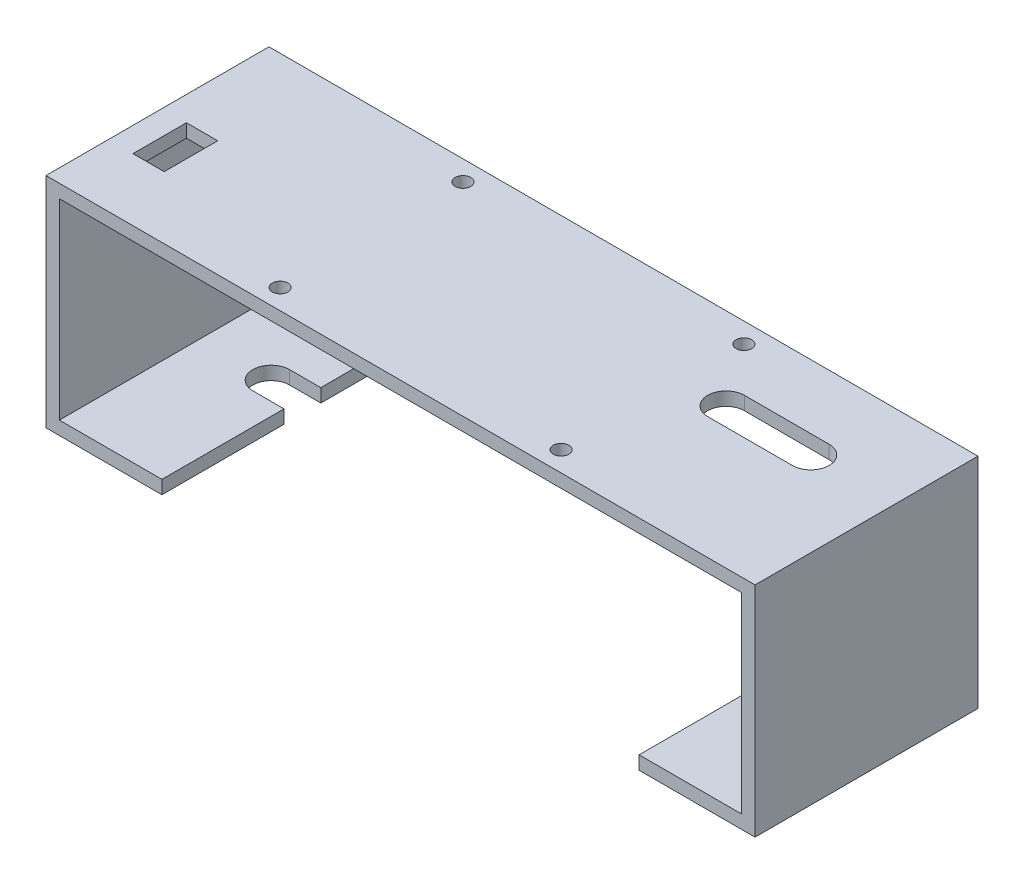
from build123d import *

# Parameters (mm, degrees)
BOSS_EXTRUDE1_DEPTH = 3
BOSS_EXTRUDE2_DEPTH = 50
CUT_EXTRUDE1_REACH  = 51
CUT_EXTRUDE2_REACH  = 5
CUT_EXTRUDE3_REACH  = 51
SKETCH7_W           = 7
SKETCH7_H           = 12
CUT_EXTRUDE5_REACH  = 51
SKETCH8_W           = 7
SKETCH8_H           = 12
CUT_EXTRUDE7_REACH  = 5
SKETCH1_R           = 1.75


with BuildPart() as part:
    # Sketch2 → Boss-Extrude1 (new body)
    with BuildSketch(Plane(origin=(0, 0, 0), x_dir=(1, 0, 0), z_dir=(0, 1, 0))):
        Polygon((-52.5, 25), (52.5, 25), (76.5, 25), (79.5, 25), (79.5, -25), (76.5, -25), (52.5, -25), (-52.5, -25), (-76.5, -25), (-79.5, -25), (-79.5, 25), (-76.5, 25), align=None)
    extrude(amount=BOSS_EXTRUDE1_DEPTH)

    # Sketch4 → Boss-Extrude2 (add)
    with BuildSketch(Plane(origin=(0, 0, -25), x_dir=(-1, 0, 0), z_dir=(0, 0, -1))):
        Polygon((79.5, 0), (79.5, -46), (53.5, -46), (53.5, -43), (76.5, -43), (76.5, 0), align=None)
    boss_extrude2 = extrude(amount=-BOSS_EXTRUDE2_DEPTH)

    # Mirror1: Boss-Extrude2 across plane
    add(boss_extrude2.mirror(Plane(origin=(0, 0, 0), x_dir=(0, 0, 1), z_dir=(1, 0, 0))))

    # Sketch5 → Cut-Extrude1 (cut, up to next)
    with BuildSketch(Plane.XZ.offset(46), mode=Mode.PRIVATE) as cut_extrude1_sk1:
        with BuildLine():
            Line((-53.5, -2.375), (-60.5, -2.375))
            ThreePointArc((-60.5, -2.375), (-64.625, -6.5), (-60.5, -10.625))
            Line((-60.5, -10.625), (-53.5, -10.625))
            Line((-53.5, -10.625), (-53.5, -2.375))
        make_face()
    cut_extrude1_tool1 = extrude(cut_extrude1_sk1.sketch, amount=-CUT_EXTRUDE1_REACH, mode=Mode.PRIVATE) & part.part
    add(cut_extrude1_tool1.solids().sort_by_distance((-58.661274, -46, -6.5))[0], mode=Mode.SUBTRACT)

    # Sketch6 → Cut-Extrude2 (cut, up to next)
    with BuildSketch(Plane.XZ, mode=Mode.PRIVATE) as cut_extrude2_sk1:
        with BuildLine():
            Line((41.5, -2.375), (60.5, -2.375))
            ThreePointArc((60.5, -2.375), (64.625, -6.5), (60.5, -10.625))
            Line((60.5, -10.625), (41.5, -10.625))
            ThreePointArc((41.5, -10.625), (37.375, -6.5), (41.5, -2.375))
        make_face()
    cut_extrude2_tool1 = extrude(cut_extrude2_sk1.sketch, amount=-CUT_EXTRUDE2_REACH, mode=Mode.PRIVATE) & part.part
    add(cut_extrude2_tool1.solids().sort_by_distance((51, 0, -6.5))[0], mode=Mode.SUBTRACT)

    # Sketch7 → Cut-Extrude3 (cut, up to next)
    with BuildSketch(Plane.XZ.offset(46), mode=Mode.PRIVATE) as cut_extrude3_sk1:
        with Locations((70.5, 5)):
            Rectangle(SKETCH7_W, SKETCH7_H)
    cut_extrude3_tool1 = extrude(cut_extrude3_sk1.sketch, amount=-CUT_EXTRUDE3_REACH, mode=Mode.PRIVATE) & part.part
    add(cut_extrude3_tool1.solids().sort_by_distance((70.5, -46, 5))[0], mode=Mode.SUBTRACT)

    # Sketch8 → Cut-Extrude5 (cut, up to next)
    with BuildSketch(Plane(origin=(0, 3, 0), x_dir=(1, 0, 0), z_dir=(0, 1, 0)), mode=Mode.PRIVATE) as cut_extrude5_sk1:
        with Locations((-70.5, -5)):
            Rectangle(SKETCH8_W, SKETCH8_H)
    cut_extrude5_tool1 = extrude(cut_extrude5_sk1.sketch, amount=-CUT_EXTRUDE5_REACH, mode=Mode.PRIVATE) & part.part
    add(cut_extrude5_tool1.solids().sort_by_distance((-70.5, 3, 5))[0], mode=Mode.SUBTRACT)

    # Sketch1 → Cut-Extrude7 (cut, up to next)
    with BuildSketch(Plane(origin=(0, 0, 0), x_dir=(1, 0, 0), z_dir=(0, 1, 0)), mode=Mode.PRIVATE) as cut_extrude7_sk1:
        with Locations((-31.5, 20.5)):
            Circle(SKETCH1_R)
    cut_extrude7_tool1 = extrude(cut_extrude7_sk1.sketch, amount=CUT_EXTRUDE7_REACH, mode=Mode.PRIVATE) & part.part
    add(cut_extrude7_tool1.solids().sort_by_distance((-31.5, 0, -20.5))[0], mode=Mode.SUBTRACT)
    # Sketch1 → Cut-Extrude7 (cut, up to next)
    with BuildSketch(Plane(origin=(0, 0, 0), x_dir=(1, 0, 0), z_dir=(0, 1, 0)), mode=Mode.PRIVATE) as cut_extrude7_sk2:
        with Locations((-31.5, -20.5)):
            Circle(SKETCH1_R)
    cut_extrude7_tool2 = extrude(cut_extrude7_sk2.sketch, amount=CUT_EXTRUDE7_REACH, mode=Mode.PRIVATE) & part.part
    add(cut_extrude7_tool2.solids().sort_by_distance((-31.5, 0, 20.5))[0], mode=Mode.SUBTRACT)
    # Sketch1 → Cut-Extrude7 (cut, up to next)
    with BuildSketch(Plane(origin=(0, 0, 0), x_dir=(1, 0, 0), z_dir=(0, 1, 0)), mode=Mode.PRIVATE) as cut_extrude7_sk3:
        with Locations((31.5, -20.5)):
            Circle(SKETCH1_R)
    cut_extrude7_tool3 = extrude(cut_extrude7_sk3.sketch, amount=CUT_EXTRUDE7_REACH, mode=Mode.PRIVATE) & part.part
    add(cut_extrude7_tool3.solids().sort_by_distance((31.5, 0, 20.5))[0], mode=Mode.SUBTRACT)
    # Sketch1 → Cut-Extrude7 (cut, up to next)
    with BuildSketch(Plane(origin=(0, 0, 0), x_dir=(1, 0, 0), z_dir=(0, 1, 0)), mode=Mode.PRIVATE) as cut_extrude7_sk4:
        with Locations((31.5, 20.5)):
            Circle(SKETCH1_R)
    cut_extrude7_tool4 = extrude(cut_extrude7_sk4.sketch, amount=CUT_EXTRUDE7_REACH, mode=Mode.PRIVATE) & part.part
    add(cut_extrude7_tool4.solids().sort_by_distance((31.5, 0, -20.5))[0], mode=Mode.SUBTRACT)


solid = part.part
